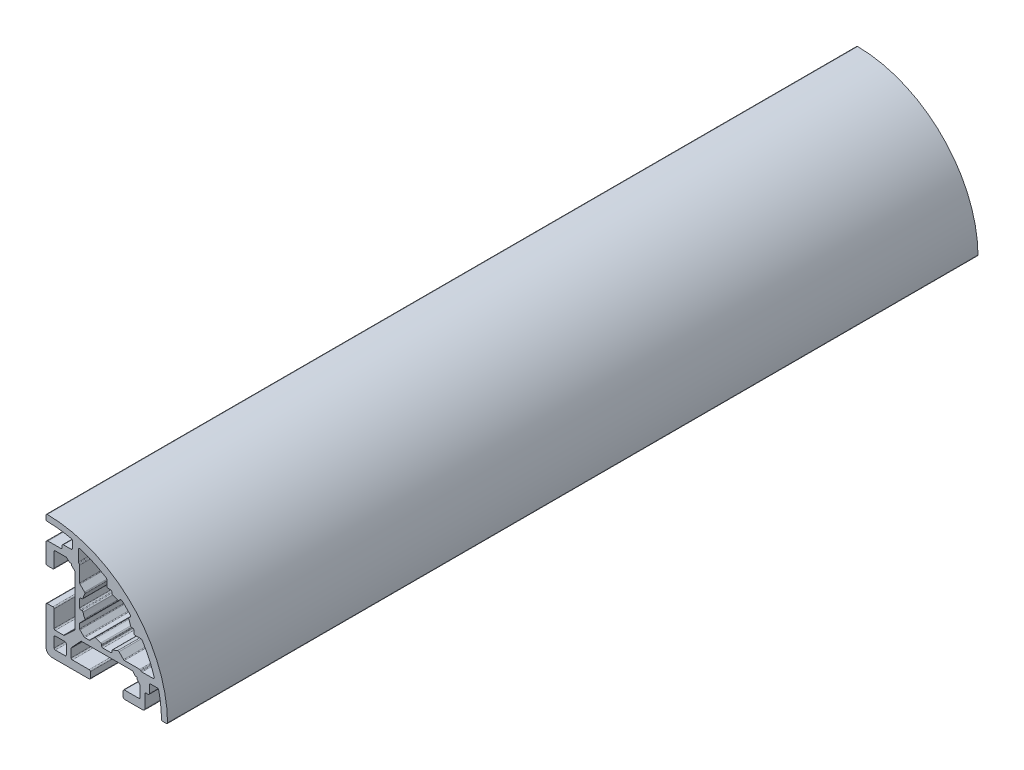
from build123d import *

# Parameters (mm, degrees)
RESSALTO_EXTRUS_O1_DEPTH = 200


with BuildPart() as part:
    # Esboço1 → Ressalto-extrusão1 (new body)
    with BuildSketch(Plane(origin=(0, 0, 0), x_dir=(-1, 0, 0), z_dir=(0, 0, -1))):
        with BuildLine():
            Line((7.988219541, 6.432338758), (8.704487641, 7.072382973))
            Line((8.704487641, 7.072382973), (8.728293149, 7.496120151))
            Line((8.728293149, 7.496120151), (9.151562381, 7.472340932))
            Line((9.151562381, 7.472340932), (9.867827891, 8.112367217))
            ThreePointArc((9.867827891, 8.112367217), (9.965155948, 8.177397462), (10.079961344, 8.200231741))
            Line((10.079961344, 8.200231741), (12.700062746, 8.200189288))
            ThreePointArc((12.700062746, 8.200189288), (12.912193499, 8.112317744), (13.000057885, 7.900184026))
            Line((13.000057885, 7.900184026), (12.999995614, 4.350227048))
            ThreePointArc((12.999995614, 4.350227048), (13.087860246, 4.138093085), (13.299991447, 4.050221785))
            Line((13.299991447, 4.050221785), (14.699990096, 4.050202343))
            ThreePointArc((14.699990096, 4.050202343), (14.912124824, 4.138068835), (14.999994262, 4.350202343))
            Line((14.999994262, 4.350202343), (14.999994262, 8.899908545))
            ThreePointArc((14.999994262, 8.899908545), (14.853547653, 9.253461936), (14.499994262, 9.399908545))
            Line((14.499994262, 9.399908545), (11.299984015, 9.399908545))
            ThreePointArc((11.299984015, 9.399908545), (11.087851981, 9.487776511), (10.999984015, 9.699908545))
            Line((10.999984015, 9.699908545), (10.999984015, 10.199939564))
            ThreePointArc((10.999984015, 10.199939564), (10.91211588, 10.412072007), (10.699983437, 10.499940142))
            Line((10.699983437, 10.499940142), (8.799996289, 10.499940142))
            ThreePointArc((8.799996289, 10.499940142), (8.587864255, 10.587808108), (8.499996289, 10.799940142))
            Line((8.499996289, 10.799940142), (8.499996289, 12.509984621))
            ThreePointArc((8.499996289, 12.509984621), (8.565702422, 12.697351597), (8.734038846, 12.802644177))
            ThreePointArc((8.734038846, 12.802644177), (11.700188414, 13.308311468), (14.703119279, 13.498440079))
            ThreePointArc((14.703119279, 13.498440079), (14.913228295, 13.587399521), (14.999994262, 13.798423803))
            Line((14.999994262, 13.798423803), (14.999994262, 14.698471418))
            ThreePointArc((14.999994262, 14.698471418), (14.911052198, 14.911672141), (14.696963943, 14.998456113))
            ThreePointArc((14.696963943, 14.998456113), (-6.213201777, 6.213195799), (-14.998473404, -14.696965168))
            ThreePointArc((-14.998473404, -14.696965168), (-14.91168949, -14.911053528), (-14.69848871, -14.99999565))
            Line((-14.69848871, -14.99999565), (-13.798441347, -14.99999565))
            ThreePointArc((-13.798441347, -14.99999565), (-13.587416943, -14.913229667), (-13.498457365, -14.70312058))
            ThreePointArc((-13.498457365, -14.70312058), (-13.308326814, -11.700187782), (-12.802657176, -8.734036533))
            ThreePointArc((-12.802657176, -8.734036533), (-12.69756035, -8.565856959), (-12.510499232, -8.499994604))
            Line((-12.510499232, -8.499994604), (-10.800466095, -8.49997976))
            ThreePointArc((-10.800466095, -8.49997976), (-10.588332377, -8.587846805), (-10.500463491, -8.79997976))
            Line((-10.500463491, -8.79997976), (-10.500463491, -10.699963204))
            ThreePointArc((-10.500463491, -10.699963204), (-10.412595525, -10.912095238), (-10.200463491, -10.999963204))
            Line((-10.200463491, -10.999963204), (-9.700412566, -10.999963204))
            ThreePointArc((-9.700412566, -10.999963204), (-9.488279549, -11.087832151), (-9.400412566, -11.299965981))
            Line((-9.400412566, -11.299965981), (-9.400442195, -14.49999102))
            ThreePointArc((-9.400442195, -14.49999102), (-9.253997222, -14.853547404), (-8.900442195, -14.99999565))
            Line((-8.900442195, -14.99999565), (-4.350452582, -14.99999565))
            ThreePointArc((-4.350452582, -14.99999565), (-4.138321038, -14.912128175), (-4.050452582, -14.699997039))
            Line((-4.050452582, -14.699997039), (-4.0504461, -13.299966156))
            ThreePointArc((-4.0504461, -13.299966156), (-4.138313069, -13.087833729), (-4.350444671, -12.999964767))
            Line((-4.350444671, -12.999964767), (-7.90045314, -12.999947852))
            ThreePointArc((-7.90045314, -12.999947852), (-8.112584733, -12.912078899), (-8.200451711, -12.699946488))
            Line((-8.200451711, -12.699946488), (-8.2004398, -10.079879081))
            ThreePointArc((-8.2004398, -10.079879081), (-8.177603139, -9.965074158), (-8.112570875, -9.867747451))
            Line((-8.112570875, -9.867747451), (-7.472516642, -9.151499458))
            Line((-7.472516642, -9.151499458), (-7.496307785, -8.728000464))
            Line((-7.496307785, -8.728000464), (-7.07269541, -8.704202951))
            Line((-7.07269541, -8.704202951), (-6.432641175, -7.987954957))
            ThreePointArc((-6.432641175, -7.987954957), (-6.33531386, -7.922923563), (-6.220508707, -7.900087947))
            Line((-6.220508707, -7.900087947), (6.219693645, -7.900145542))
            ThreePointArc((6.219693645, -7.900145542), (6.33449792, -7.922981945), (6.431824279, -7.988013496))
            Line((6.431824279, -7.988013496), (8.71172379, -10.467916072))
            ThreePointArc((8.71172379, -10.467916072), (8.776761952, -10.565245573), (8.799600807, -10.680055769))
            Line((8.799600807, -10.680055769), (8.79961016, -12.700073336))
            ThreePointArc((8.79961016, -12.700073336), (8.711742982, -12.912205971), (8.499611001, -13.000074725))
            Line((8.499611001, -13.000074725), (4.349602, -13.000086362))
            ThreePointArc((4.349602, -13.000086362), (4.137471001, -13.087954134), (4.049602841, -13.300084973))
            Line((4.049602841, -13.300084973), (4.04959636, -14.699994261))
            ThreePointArc((4.04959636, -14.699994261), (4.137463835, -14.912127193), (4.349596361, -14.99999565))
            Line((4.349596361, -14.99999565), (13.499994262, -14.99999565))
            ThreePointArc((13.499994262, -14.99999565), (14.560654434, -14.560655822), (14.999994262, -13.49999565))
            Line((14.999994262, -13.49999565), (14.999994262, -4.349951929))
            ThreePointArc((14.999994262, -4.349951929), (14.912126297, -4.137819895), (14.699994262, -4.049951929))
            Line((14.699994262, -4.049951929), (13.299941692, -4.049951929))
            ThreePointArc((13.299941692, -4.049951929), (13.087809804, -4.137819748), (12.999941692, -4.349951515))
            Line((12.999941692, -4.349951515), (12.999935957, -8.499908737))
            ThreePointArc((12.999935957, -8.499908737), (12.9120676, -8.712040749), (12.699935263, -8.799908323))
            Line((12.699935263, -8.799908323), (10.679833904, -8.799903647))
            ThreePointArc((10.679833904, -8.799903647), (10.565028929, -8.777067242), (10.467702076, -8.712035194))
            Line((10.467702076, -8.712035194), (7.987808147, -6.432129961))
            ThreePointArc((7.987808147, -6.432129961), (7.922994822, -6.334753653), (7.900348133, -6.219992858))
            Line((7.900348133, -6.219992858), (7.900348133, 6.220203281))
            ThreePointArc((7.900348133, 6.220203281), (7.923185205, 6.33501056), (7.988219541, 6.432338758))
        make_face()
        with BuildLine():
            Line((12.699997649, -12.999995366), (10.299997649, -12.999995366))
            ThreePointArc((10.299997649, -12.999995366), (10.087865615, -12.9121274), (9.999997649, -12.699995366))
            Line((9.999997649, -12.699995366), (9.999997649, -10.299995366))
            ThreePointArc((9.999997649, -10.299995366), (10.087865615, -10.087863332), (10.299997649, -9.999995366))
            Line((10.299997649, -9.999995366), (12.699997649, -9.999995366))
            ThreePointArc((12.699997649, -9.999995366), (12.912129683, -10.087863332), (12.999997649, -10.299995366))
            Line((12.999997649, -10.299995366), (12.999997649, -12.699995366))
            ThreePointArc((12.999997649, -12.699995366), (12.912129683, -12.9121274), (12.699997649, -12.999995366))
        make_face(mode=Mode.SUBTRACT)
        with BuildLine():
            Line((-0.949997542, 6.699991608), (-0.300006198, 6.699991608))
            ThreePointArc((-0.300006198, 6.699991608), (-0.087874164, 6.787859574), (-6.198e-06, 6.999991608))
            Line((-6.198e-06, 6.999991608), (-6.198e-06, 8.47764802))
            ThreePointArc((-6.198e-06, 8.47764802), (0.037542168, 8.622972279), (0.140788069, 8.731918614))
            ThreePointArc((0.140788069, 8.731918614), (3.280244614, 10.429262729), (6.61010457, 11.713473425))
            ThreePointArc((6.61010457, 11.713473425), (6.877524397, 11.669091748), (6.999996226, 11.427257614))
            Line((6.999996226, 11.427257614), (6.999996226, 8.679894243))
            ThreePointArc((6.999996226, 8.679894243), (6.977160088, 8.565089218), (6.912128268, 8.467762216))
            Line((6.912128268, 8.467762216), (6.787851146, 8.343485086))
            ThreePointArc((6.787851146, 8.343485086), (6.722819326, 8.246158084), (6.699983188, 8.131353059))
            Line((6.699983188, 8.131353059), (6.699983188, 4.349373523))
            ThreePointArc((6.699983188, 4.349373523), (6.677147048, 4.234568493), (6.612115222, 4.137241489))
            Line((6.612115222, 4.137241489), (5.487142739, 3.012269005))
            ThreePointArc((5.487142739, 3.012269005), (5.403317864, 2.849223708), (5.430017697, 2.667847035))
            ThreePointArc((5.430017697, 2.667847035), (5.679815237, 2.083794343), (5.866996881, 1.47676931))
            ThreePointArc((5.866996881, 1.47676931), (5.973488711, 1.313387662), (6.157922346, 1.249997541))
            Line((6.157922346, 1.249997541), (6.399983188, 1.249997541))
            ThreePointArc((6.399983188, 1.249997541), (6.612115222, 1.162129575), (6.699983188, 0.949997541))
            Line((6.699983188, 0.949997541), (6.699983188, -0.949997542))
            ThreePointArc((6.699983188, -0.949997542), (6.612115222, -1.162129576), (6.399983188, -1.249997542))
            Line((6.399983188, -1.249997542), (6.157922346, -1.249997542))
            ThreePointArc((6.157922346, -1.249997542), (5.973488711, -1.313387663), (5.866996881, -1.476769311))
            ThreePointArc((5.866996881, -1.476769311), (5.679815237, -2.083794344), (5.430017697, -2.667847036))
            ThreePointArc((5.430017697, -2.667847036), (5.403317864, -2.849223709), (5.487142739, -3.012269006))
            Line((5.487142739, -3.012269006), (6.612115222, -4.13724149))
            ThreePointArc((6.612115222, -4.13724149), (6.677147048, -4.234568494), (6.699983188, -4.349373524))
            Line((6.699983188, -4.349373524), (6.699983188, -5.439573887))
            ThreePointArc((6.699983188, -5.439573887), (6.677147048, -5.554378917), (6.612115222, -5.651705921))
            Line((6.612115222, -5.651705921), (5.651680826, -6.612140317))
            ThreePointArc((5.651680826, -6.612140317), (5.554353822, -6.677172143), (5.439548792, -6.700008283))
            Line((5.439548792, -6.700008283), (4.349398617, -6.700008283))
            ThreePointArc((4.349398617, -6.700008283), (4.234593588, -6.677172143), (4.137266583, -6.612140317))
            Line((4.137266583, -6.612140317), (3.012269005, -5.48714274))
            ThreePointArc((3.012269005, -5.48714274), (2.849223708, -5.403317864), (2.667847035, -5.430017698))
            ThreePointArc((2.667847035, -5.430017698), (2.083794343, -5.679815238), (1.47676931, -5.866996882))
            ThreePointArc((1.47676931, -5.866996882), (1.313387662, -5.973488713), (1.24999754, -6.157922347))
            Line((1.24999754, -6.157922347), (1.24999754, -6.400008283))
            ThreePointArc((1.24999754, -6.400008283), (1.162129575, -6.612140317), (0.94999754, -6.700008283))
            Line((0.94999754, -6.700008283), (-0.949997542, -6.700008283))
            ThreePointArc((-0.949997542, -6.700008283), (-1.162129576, -6.612140317), (-1.249997542, -6.400008283))
            Line((-1.249997542, -6.400008283), (-1.249997542, -6.157922347))
            ThreePointArc((-1.249997542, -6.157922347), (-1.313387663, -5.973488713), (-1.476769311, -5.866996882))
            ThreePointArc((-1.476769311, -5.866996882), (-2.083794344, -5.679815238), (-2.667847036, -5.430017698))
            ThreePointArc((-2.667847036, -5.430017698), (-2.849223709, -5.403317865), (-3.012269006, -5.48714274))
            Line((-3.012269006, -5.48714274), (-4.137266583, -6.612140317))
            ThreePointArc((-4.137266583, -6.612140317), (-4.234593588, -6.677172143), (-4.349398618, -6.700008283))
            Line((-4.349398618, -6.700008283), (-8.131377093, -6.700008283))
            ThreePointArc((-8.131377093, -6.700008283), (-8.246182127, -6.722844425), (-8.343509135, -6.787876256))
            Line((-8.343509135, -6.787876256), (-8.467778577, -6.912145707))
            ThreePointArc((-8.467778577, -6.912145707), (-8.565105584, -6.977177538), (-8.679910619, -7.00001368))
            Line((-8.679910619, -7.00001368), (-11.427275069, -7.00001368))
            ThreePointArc((-11.427275069, -7.00001368), (-11.669109203, -6.877541852), (-11.713490879, -6.610122025))
            ThreePointArc((-11.713490879, -6.610122025), (-10.429280184, -3.280262068), (-8.731936068, -0.140805524))
            ThreePointArc((-8.731936068, -0.140805524), (-8.622989733, -0.037559623), (-8.477665474, -1.1256e-05))
            Line((-8.477665474, -1.1256e-05), (-7.000004228, -1.1256e-05))
            ThreePointArc((-7.000004228, -1.1256e-05), (-6.787872194, 0.08785671), (-6.700004228, 0.299988744))
            Line((-6.700004228, 0.299988744), (-6.700004228, 0.94999754))
            ThreePointArc((-6.700004228, 0.94999754), (-6.612136263, 1.162129574), (-6.400004228, 1.24999754))
            Line((-6.400004228, 1.24999754), (-6.157922347, 1.24999754))
            ThreePointArc((-6.157922347, 1.24999754), (-5.973488713, 1.313387661), (-5.866996882, 1.476769309))
            ThreePointArc((-5.866996882, 1.476769309), (-5.679815238, 2.083794343), (-5.430017698, 2.667847035))
            ThreePointArc((-5.430017698, 2.667847035), (-5.403317865, 2.849223708), (-5.48714274, 3.012269005))
            Line((-5.48714274, 3.012269005), (-5.797444779, 3.322571045))
            ThreePointArc((-5.797444779, 3.322571045), (-5.885209902, 3.526848471), (-5.808258232, 3.735439996))
            ThreePointArc((-5.808258232, 3.735439996), (-4.798993375, 4.798993588), (-3.735438882, 5.808257496))
            ThreePointArc((-3.735438882, 5.808257496), (-3.526847423, 5.885208983), (-3.322570131, 5.797443864))
            Line((-3.322570131, 5.797443864), (-3.012269006, 5.487142739))
            ThreePointArc((-3.012269006, 5.487142739), (-2.849223709, 5.403317864), (-2.667847036, 5.430017697))
            ThreePointArc((-2.667847036, 5.430017697), (-2.083794344, 5.679815237), (-1.476769311, 5.866996881))
            ThreePointArc((-1.476769311, 5.866996881), (-1.313387663, 5.973488711), (-1.249997542, 6.157922346))
            Line((-1.249997542, 6.157922346), (-1.249997542, 6.399991608))
            ThreePointArc((-1.249997542, 6.399991608), (-1.162129576, 6.612123643), (-0.949997542, 6.699991608))
        make_face(mode=Mode.SUBTRACT)
    extrude(amount=-RESSALTO_EXTRUS_O1_DEPTH)


solid = part.part
